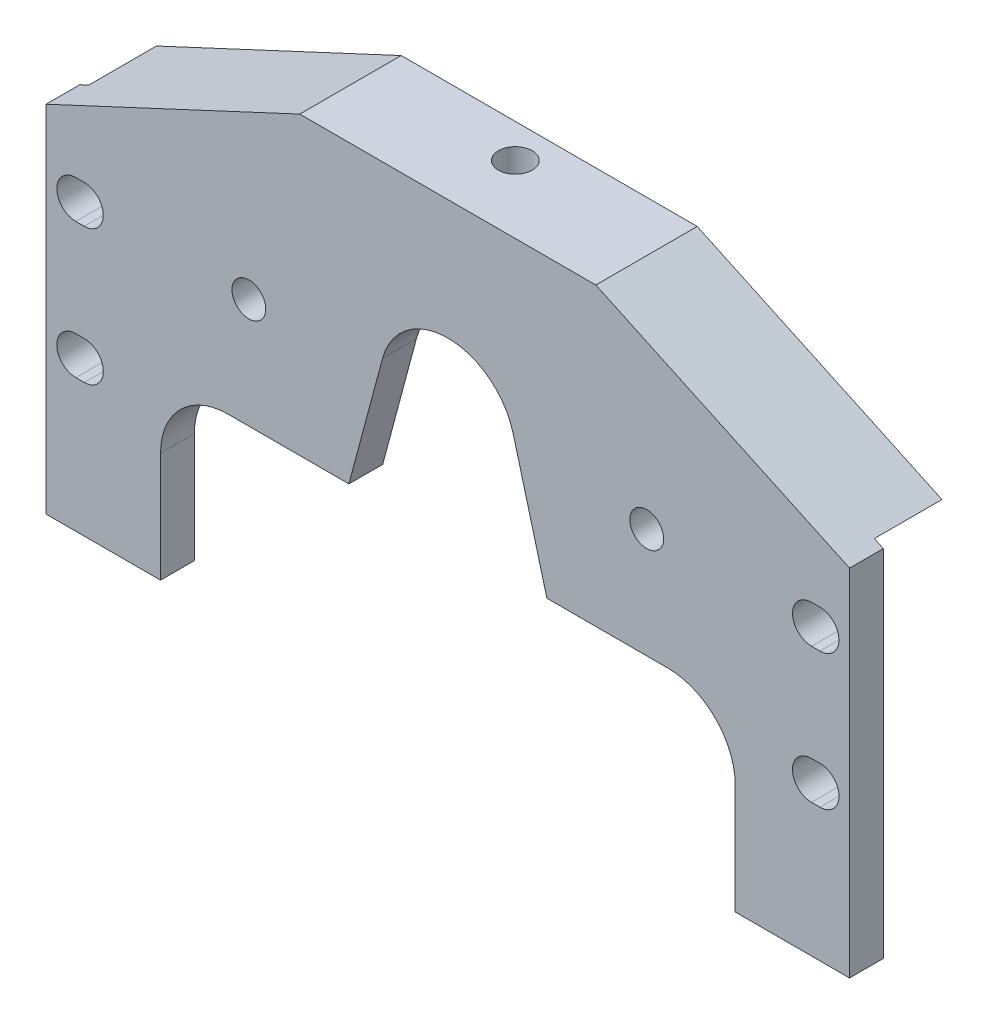
from build123d import *

# Parameters (mm, degrees)
BASE_EXTRUDE_DEPTH             = 12.7
F_9_16_0_5625_DIAMETER_HOLE1_D = 14.2875
CUT_EXTRUDE1_REACH             = 14.7
BOSS_EXTRUDE1_DEPTH            = 25.4
F_1_2_20_TAPPED_HOLE1_D        = 12.7
CUT_EXTRUDE2_DEPTH             = 39.1
CUT_EXTRUDE3_DEPTH             = 39.1
F_1_2_20_TAPPED_HOLE2_D        = 12.7
CUT_EXTRUDE4_DEPTH             = 25.4


with BuildPart() as part:
    # Sketch1 → Base-Extrude (new body)
    with BuildSketch(Plane.XY):
        Polygon((58.12164787, 111.098459585), (-37.201684746, 66.648459585), (-37.201684746, -66.701540415), (264.657388756, -66.701540415), (264.657388756, 66.648459585), (169.334056139, 111.098459585), align=None)
    extrude(amount=BASE_EXTRUDE_DEPTH)

    # 9/16 (0.5625) Diameter Hole1 (through all)
    with Locations(Plane.XY.offset(12.7)):
        with Locations((251.957388756, -9.551540415), (251.957388756, 41.248459585)):
            f_9_16_0_5625_diameter_hole1 = Hole(F_9_16_0_5625_DIAMETER_HOLE1_D / 2)

    # Sketch8 → Cut-Extrude1 (cut, up to next)
    with BuildSketch(Plane.XY.offset(12.7), mode=Mode.PRIVATE) as cut_extrude1_sk1:
        with BuildLine():
            Line((5.818295254, -25.4), (5.818295254, -66.701540415))
            Line((5.818295254, -66.701540415), (221.718295254, -66.701540415))
            Line((221.718295254, -66.701540415), (221.718295254, -25.4))
            ThreePointArc((221.718295254, -25.4), (214.278807496, -7.439487758), (196.318295254, 0))
            Line((196.318295254, 0), (150.956476278, 0))
            Line((150.956476278, 0), (138.302811241, 47.224120819))
            ThreePointArc((138.302811241, 47.224120819), (113.768295254, 66.050117074), (89.233779266, 47.224120819))
            Line((89.233779266, 47.224120819), (76.580114229, 0))
            Line((76.580114229, 0), (31.218295254, 0))
            ThreePointArc((31.218295254, 0), (13.257783011, -7.439487758), (5.818295254, -25.4))
        make_face()
    cut_extrude1_tool1 = extrude(cut_extrude1_sk1.sketch, amount=-CUT_EXTRUDE1_REACH, mode=Mode.PRIVATE) & part.part
    add(cut_extrude1_tool1.solids().sort_by_distance((113.768295, -21.271265, 12.7))[0], mode=Mode.SUBTRACT)

    # Mirror3: 9/16 (0.5625) Diameter Hole1 across plane
    add(f_9_16_0_5625_diameter_hole1.mirror(Plane(origin=(113.768295254, 0, 0), x_dir=(0, 0, 1), z_dir=(1, 0, 0))), mode=Mode.SUBTRACT)

    # Sketch10 → Boss-Extrude1 (add)
    with BuildSketch(Plane(origin=(0, 0, 0), x_dir=(-1, 0, 0), z_dir=(0, 0, -1))):
        Polygon((-169.334056139, 111.098459585), (-58.12164787, 111.098459585), (33.824515248, 68.223259585), (-261.280219258, 68.223259585), align=None)
    extrude(amount=BOSS_EXTRUDE1_DEPTH)

    # 1/2-20 Tapped Hole1 (through all)
    with Locations(Plane(origin=(0, 111.098459585, 0), x_dir=(-1, 0, 0), z_dir=(0, 1, 0))):
        with Locations((-113.69684787, -12.7)):
            Hole(F_1_2_20_TAPPED_HOLE1_D / 2)

    # Sketch13 → Cut-Extrude2 (cut, through all)
    with BuildSketch(Plane.XY.offset(12.7)):
        with BuildLine():
            Line((250.369888756, -2.407790415), (253.544888756, -2.407790415))
            ThreePointArc((253.544888756, -2.407790415), (260.688638756, -9.551540415), (253.544888756, -16.695290415))
            Line((253.544888756, -16.695290415), (250.369888756, -16.695290415))
            ThreePointArc((250.369888756, -16.695290415), (243.226138756, -9.551540415), (250.369888756, -2.407790415))
        make_face()
    cut_extrude2 = extrude(amount=-CUT_EXTRUDE2_DEPTH, mode=Mode.SUBTRACT)

    # Sketch14 → Cut-Extrude3 (cut, through all)
    with BuildSketch(Plane.XY.offset(12.7)):
        with BuildLine():
            Line((253.532188756, 48.392209585), (250.382588756, 48.392209585))
            ThreePointArc((250.382588756, 48.392209585), (243.238838756, 41.248459585), (250.382588756, 34.104709585))
            Line((250.382588756, 34.104709585), (253.532188756, 34.104709585))
            ThreePointArc((253.532188756, 34.104709585), (260.675938756, 41.248459585), (253.532188756, 48.392209585))
        make_face()
    cut_extrude3 = extrude(amount=-CUT_EXTRUDE3_DEPTH, mode=Mode.SUBTRACT)

    # Mirror4: Cut-Extrude2, Cut-Extrude3 across plane
    add(cut_extrude2.mirror(Plane(origin=(113.768295254, 0, 0), x_dir=(0, 0, 1), z_dir=(1, 0, 0))), mode=Mode.SUBTRACT)
    add(cut_extrude3.mirror(Plane(origin=(113.768295254, 0, 0), x_dir=(0, 0, 1), z_dir=(1, 0, 0))), mode=Mode.SUBTRACT)

    # 1/2-20 Tapped Hole2 (through all)
    with Locations(Plane.XY.offset(12.7)):
        with Locations((38.998315254, 41.248459585), (188.457388756, 41.248459585)):
            Hole(F_1_2_20_TAPPED_HOLE2_D / 2)

    # Sketch17 → Cut-Extrude4 (cut)
    with BuildSketch(Plane(origin=(0, 0, -25.4), x_dir=(-1, 0, 0), z_dir=(0, 0, -1))):
        with BuildLine():
            Line((-132.777852005, 68.223259585), (-94.677852005, 68.223259585))
            Line((-94.677852005, 68.223259585), (-94.677852005, 87.273259585))
            ThreePointArc((-94.677852005, 87.273259585), (-97.467659914, 94.008451676), (-104.202852005, 96.798259585))
            Line((-104.202852005, 96.798259585), (-123.252852005, 96.798259585))
            ThreePointArc((-123.252852005, 96.798259585), (-129.988044096, 94.008451676), (-132.777852005, 87.273259585))
            Line((-132.777852005, 87.273259585), (-132.777852005, 68.223259585))
        make_face()
    extrude(amount=-CUT_EXTRUDE4_DEPTH, mode=Mode.SUBTRACT)


solid = part.part
